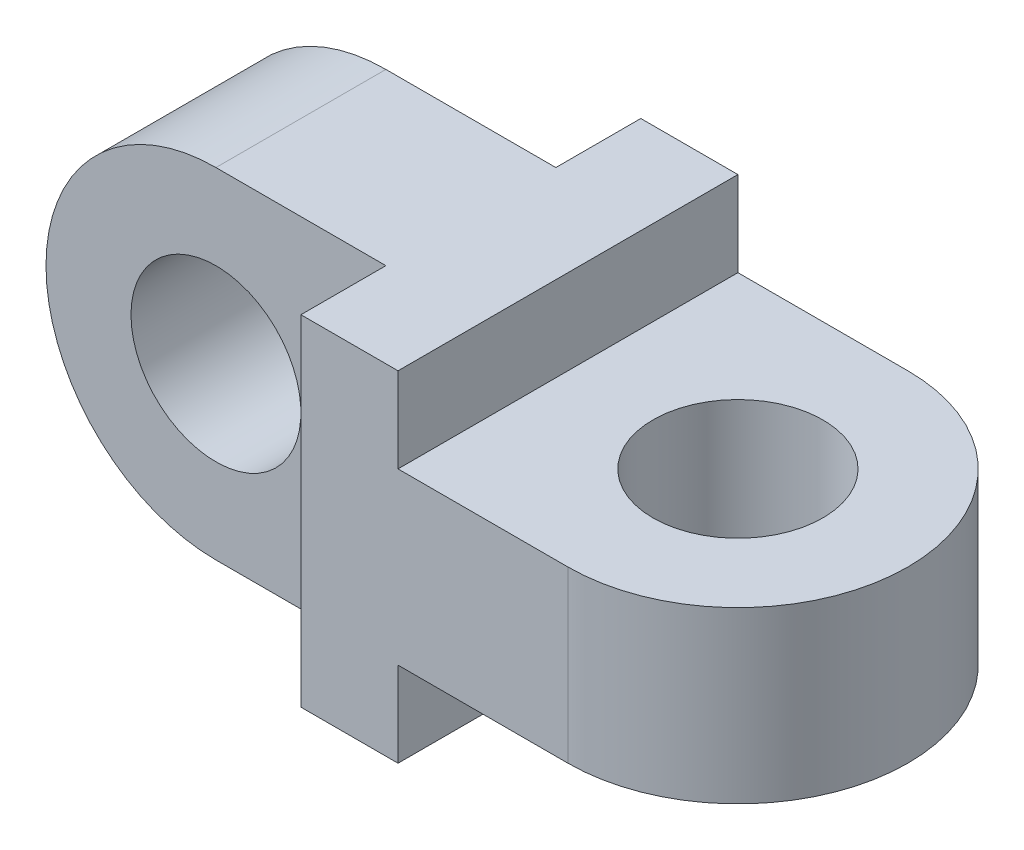
from build123d import *

# Parameters (mm, degrees)
SKETCH1_R           = 7
BOSS_EXTRUDE1_DEPTH = 7
SKETCH2_W           = 28
SKETCH2_H           = 28
BOSS_EXTRUDE2_DEPTH = 8
SKETCH3_R           = 7
BOSS_EXTRUDE3_DEPTH = 7


with BuildPart() as part:
    # Sketch1 → Boss-Extrude1 (new body, symmetric)
    with BuildSketch(Plane(origin=(0, 0, 0), x_dir=(1, 0, 0), z_dir=(0, 1, 0))):
        with BuildLine():
            Line((0, 14), (0, -14))
            Line((0, -14), (14, -14))
            ThreePointArc((14, -14), (28, 0), (14, 14))
            Line((14, 14), (0, 14))
        make_face()
        with Locations((14, 0)):
            Circle(SKETCH1_R, mode=Mode.SUBTRACT)
    extrude(amount=BOSS_EXTRUDE1_DEPTH, both=True)

    # Sketch2 → Boss-Extrude2 (add)
    with BuildSketch(Plane.ZY):
        Rectangle(SKETCH2_W, SKETCH2_H)
    extrude(amount=BOSS_EXTRUDE2_DEPTH)

    # Sketch3 → Boss-Extrude3 (add, symmetric)
    with BuildSketch(Plane(origin=(0, 0, 0), x_dir=(-1, 0, 0), z_dir=(0, 0, -1))):
        with BuildLine():
            Line((8, 14), (8, -14))
            Line((8, -14), (22, -14))
            ThreePointArc((22, -14), (36, 0), (22, 14))
            Line((22, 14), (8, 14))
        make_face()
        with Locations((22, 0)):
            Circle(SKETCH3_R, mode=Mode.SUBTRACT)
    extrude(amount=BOSS_EXTRUDE3_DEPTH, both=True)


solid = part.part
